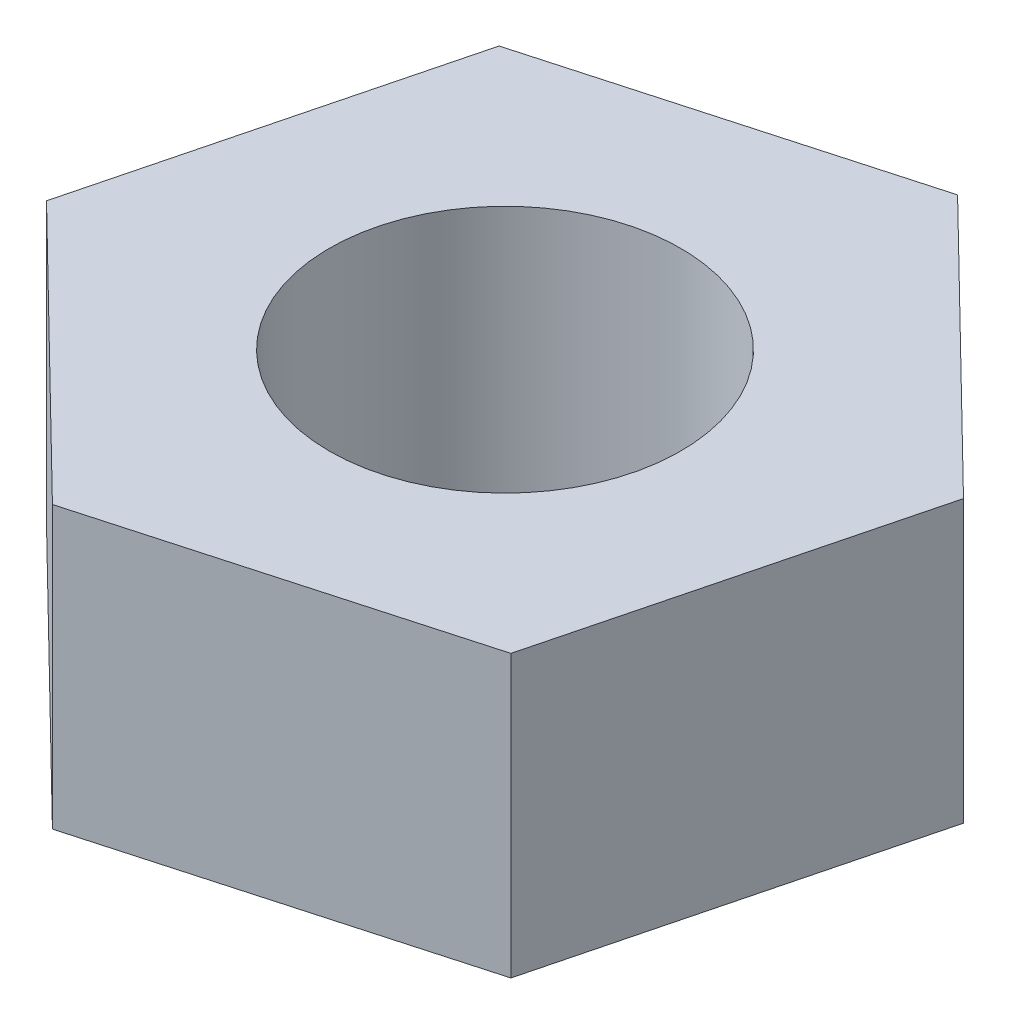
from build123d import *

# Parameters (mm, degrees)
SKETCH_1_R      = 1.5
EXTRUDE_1_DEPTH = 2.4


with BuildPart() as part:
    # 草图1 → 凸台-拉伸1 (new body)
    with BuildSketch(Plane(origin=(0, 0, 0), x_dir=(1, 0, 0), z_dir=(0, 1, 0))):
        Polygon((2.270451111, -2.219996641), (3.057799043, 0.856270019), (0.787347933, 3.07626666), (-2.270451111, 2.219996641), (-3.057799043, -0.856270019), (-0.787347933, -3.07626666), align=None)
        Circle(SKETCH_1_R, mode=Mode.SUBTRACT)
    extrude(amount=EXTRUDE_1_DEPTH)


solid = part.part
